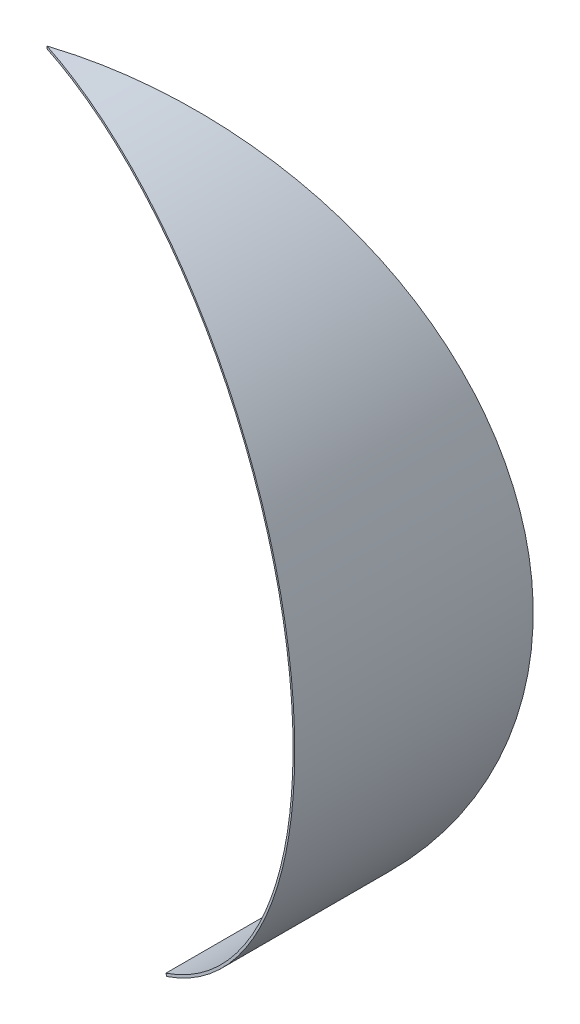
from build123d import *

# Parameters (mm, degrees)
AUFSATZ_LINEAR_AUSTRAGEN3_DEPTH      = 1500
AUFSATZ_LINEAR_AUSTRAGEN3_DEPTH_BACK = 1500
SCHNITT_LINEAR_AUSTRAGEN4_DEPTH      = 6458
SCHNITT_LINEAR_AUSTRAGEN14_DEPTH     = 6458


with BuildPart() as part:
    # Skizze1 → Aufsatz-Linear austragen3 (new body, two sides)
    with BuildSketch(Plane.XY) as aufsatz_linear_austragen3_sk:
        with BuildLine():
            Line((0, 2980), (0, 3000))
            ThreePointArc((0, 3000), (2905.075523287, 748.689658002), (1450, -2626.309197334))
            Line((1450, -2626.309197334), (1440.333333333, -2608.800469352))
            ThreePointArc((1440.333333333, -2608.800469352), (2885.708353132, 743.698393615), (0, 2980))
        make_face()
    extrude(amount=AUFSATZ_LINEAR_AUSTRAGEN3_DEPTH)
    extrude(aufsatz_linear_austragen3_sk.sketch, amount=-AUFSATZ_LINEAR_AUSTRAGEN3_DEPTH_BACK)

    # Skizze7 → Schnitt-Linear austragen4 (cut)
    with BuildSketch(Plane(origin=(0, -3000, 0), x_dir=(1, 0, 0), z_dir=(0, 1, 0))):
        Polygon((3541.107848253, -1150.575686383), (0, 0), (0, -1500), (3541.107848253, -1500), align=None)
    extrude(amount=SCHNITT_LINEAR_AUSTRAGEN4_DEPTH, mode=Mode.SUBTRACT)

    # Skizze9 → Schnitt-Linear austragen14 (cut)
    with BuildSketch(Plane(origin=(0, -3000, 0), x_dir=(1, 0, 0), z_dir=(0, 1, 0))):
        Polygon((0, 0), (2853.169548885, 927.050983125), (3389.262998564, 1101.238303947), (3389.262998564, 1500), (0, 1500), align=None)
    extrude(amount=SCHNITT_LINEAR_AUSTRAGEN14_DEPTH, mode=Mode.SUBTRACT)


solid = part.part
